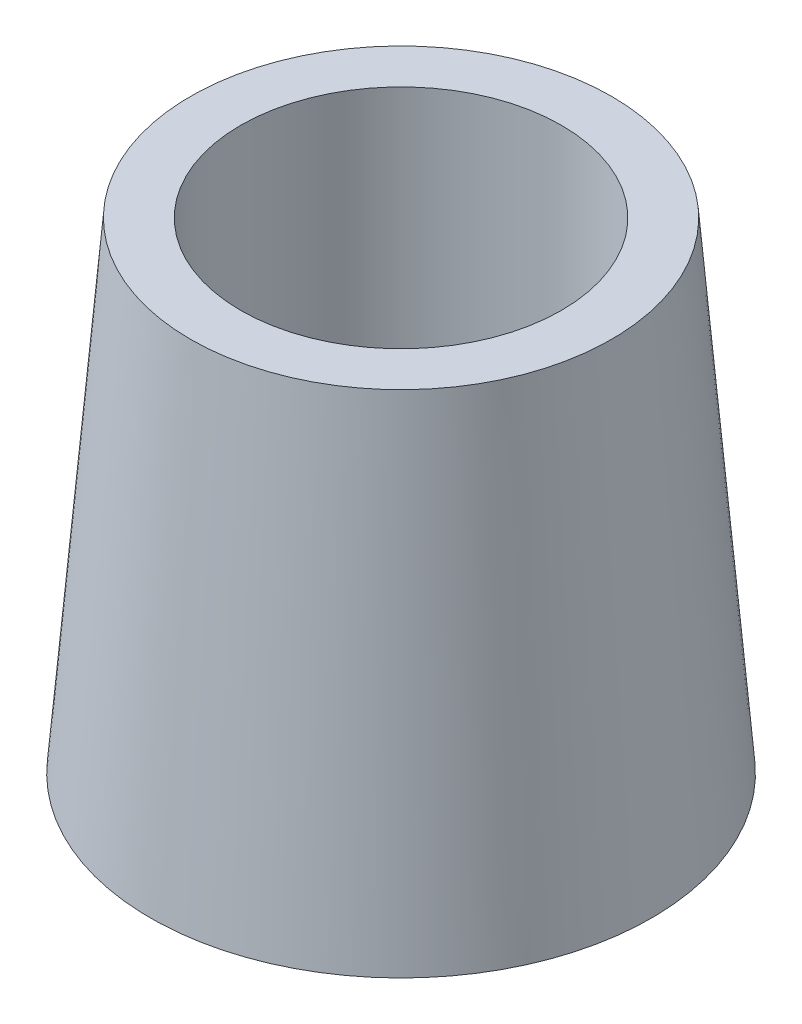
from build123d import *


with BuildPart() as part:
    # Sketch1 → Revolve1 (revolve)
    with BuildSketch(Plane.XY):
        Polygon((8, 0), (12.5, 0), (10.5, 24), (8, 24), align=None)
    revolve(axis=Axis((0, 0, 0), (0, 1, 0)))


solid = part.part
